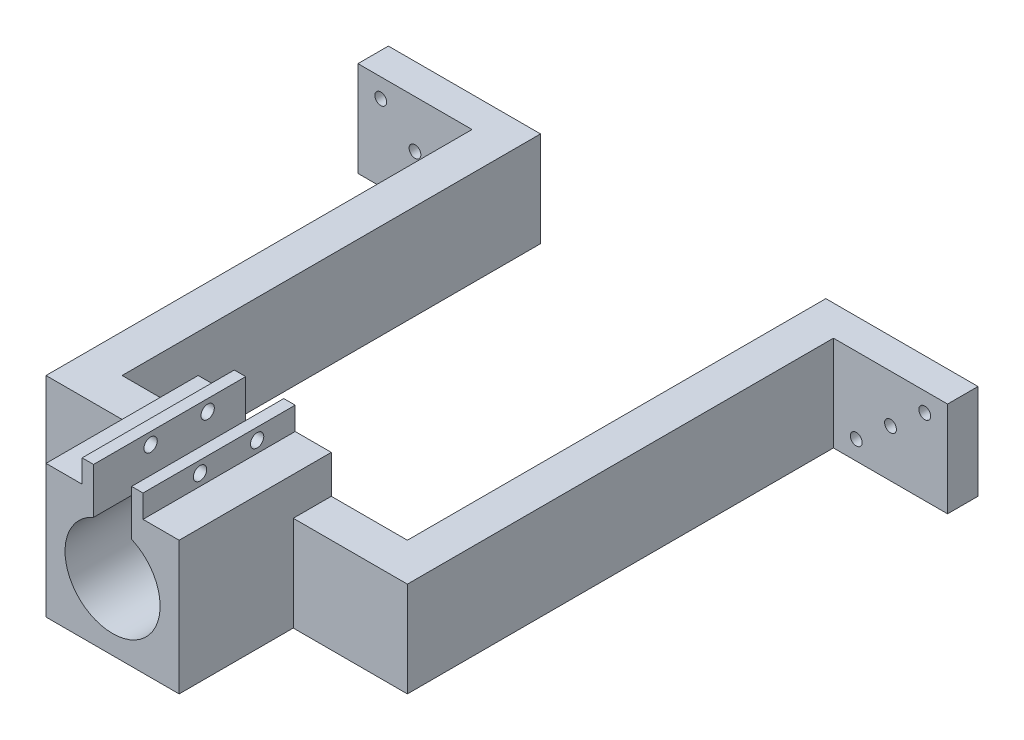
from build123d import *

# Parameters (mm, degrees)
SKETCH1_W           = 3
SKETCH1_H           = 6
BOSS_EXTRUDE1_DEPTH = 40
SKETCH2_R           = 1.75
CUT_EXTRUDE1_DEPTH  = 20
SKETCH1_3_W         = 30
SKETCH1_3_H         = 25
BOSS_EXTRUDE2_DEPTH = 10
SKETCH1_5_W         = 10
SKETCH1_5_H         = 25
BOSS_EXTRUDE3_DEPTH = 110
BOSS_EXTRUDE8_START = -110
SKETCH1_8_W         = 30
SKETCH1_8_H         = 25
SKETCH1_8_R         = 1.55
BOSS_EXTRUDE8_DEPTH = 8


with BuildPart() as part:
    # Sketch1 → Boss-Extrude1 (new body)
    with BuildSketch(Plane.XY):
        with BuildLine():
            Line((5, 17.5), (5, 11.456439237))
            ThreePointArc((5, 11.456439237), (10.458250332, 6.846531969), (12.5, 0))
            ThreePointArc((12.5, 0), (-6.846531969, -10.458250332), (-5, 11.456439237))
            Line((-5, 11.456439237), (-5, 17.5))
            Line((-5, 17.5), (-8, 17.5))
            Line((-8, 17.5), (-17.5, 17.5))
            Line((-17.5, 17.5), (-17.5, 7.5))
            Line((-17.5, 7.5), (-17.5, -17.5))
            Line((-17.5, -17.5), (17.5, -17.5))
            Line((17.5, -17.5), (17.5, 7.5))
            Line((17.5, 7.5), (17.5, 17.5))
            Line((17.5, 17.5), (8, 17.5))
            Line((8, 17.5), (5, 17.5))
        make_face()
        with Locations((-6.5, 20.5)):
            Rectangle(SKETCH1_W, SKETCH1_H)
        with Locations((6.5, 20.5)):
            Rectangle(SKETCH1_W, SKETCH1_H)
    extrude(amount=BOSS_EXTRUDE1_DEPTH)

    # Sketch2 → Cut-Extrude1 (cut)
    with BuildSketch(Plane(origin=(8, 0, 0), x_dir=(0, 0, -1), z_dir=(1, 0, 0))):
        with Locations((-25, 20.5)):
            Circle(SKETCH2_R)
        with Locations((-10, 20.5)):
            Circle(SKETCH2_R)
    extrude(amount=-CUT_EXTRUDE1_DEPTH, mode=Mode.SUBTRACT)

    # Sketch1_3 → Boss-Extrude2 (add)
    with BuildSketch(Plane.XY):
        with Locations((32.5, -5)):
            Rectangle(SKETCH1_3_W, SKETCH1_3_H)
        with Locations((-32.5, -5)):
            Rectangle(SKETCH1_3_W, SKETCH1_3_H)
    extrude(amount=BOSS_EXTRUDE2_DEPTH)

    # Sketch1_5 → Boss-Extrude3 (add)
    with BuildSketch(Plane.XY):
        with Locations((-42.5, -5)):
            Rectangle(SKETCH1_5_W, SKETCH1_5_H)
        with Locations((42.5, -5)):
            Rectangle(SKETCH1_5_W, SKETCH1_5_H)
    extrude(amount=-BOSS_EXTRUDE3_DEPTH)

    # Sketch1_8 → Boss-Extrude8 (add)
    with BuildSketch(Plane.XY.offset(BOSS_EXTRUDE8_START)):
        with Locations((62.5, -5)):
            Rectangle(SKETCH1_8_W, SKETCH1_8_H)
        with Locations((53.5, -12.5)):
            Circle(SKETCH1_8_R, mode=Mode.SUBTRACT)
        with Locations((62.5, -5)):
            Circle(SKETCH1_8_R, mode=Mode.SUBTRACT)
        with Locations((71.5, 2.5)):
            Circle(SKETCH1_8_R, mode=Mode.SUBTRACT)
        with Locations((-62.5, -5)):
            Rectangle(SKETCH1_8_W, SKETCH1_8_H)
        with Locations((-53.5, -12.5)):
            Circle(SKETCH1_8_R, mode=Mode.SUBTRACT)
        with Locations((-62.5, -5)):
            Circle(SKETCH1_8_R, mode=Mode.SUBTRACT)
        with Locations((-71.5, 2.5)):
            Circle(SKETCH1_8_R, mode=Mode.SUBTRACT)
    extrude(amount=BOSS_EXTRUDE8_DEPTH)


solid = part.part
